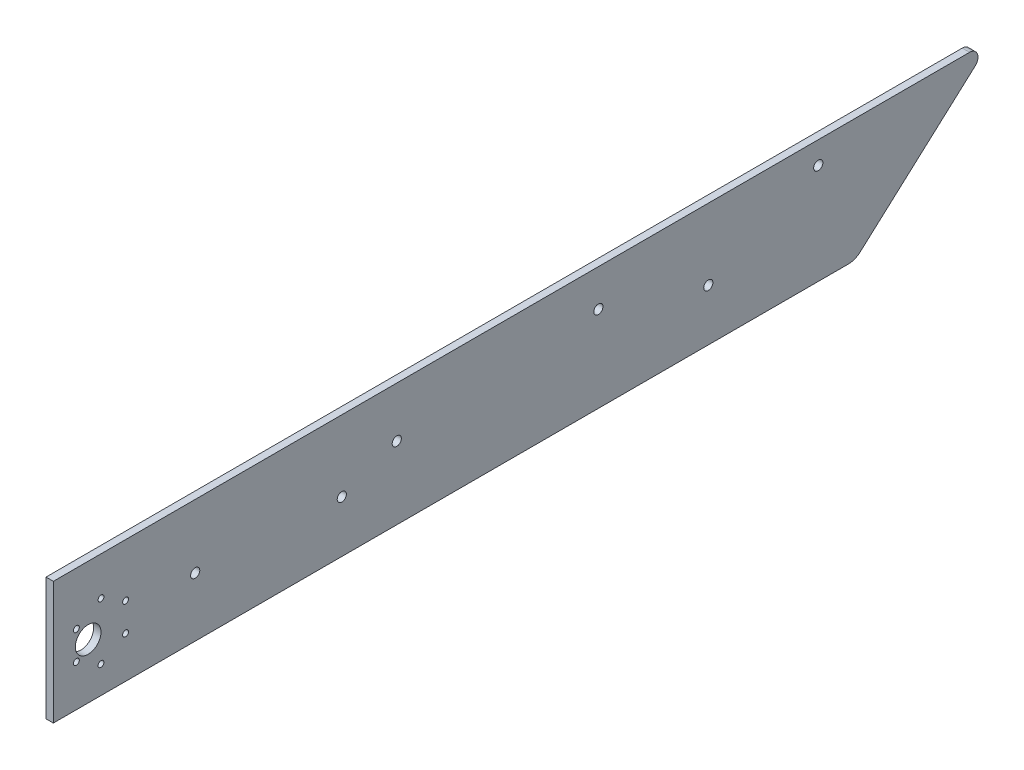
from build123d import *

# Parameters (mm, degrees)
SKETCH_1_R      = 2.5
SKETCH_1_R_2    = 7
SKETCH_1_R_3    = 1.6
EXTRUDE_1_DEPTH = 4


with BuildPart() as part:
    # 草图1 → 凸台-拉伸1 (new body)
    with BuildSketch(Plane.ZY):
        with BuildLine():
            Line((-207.252247772, -7.404631077), (226.406668198, -7.404631077))
            Line((226.406668198, -7.404631077), (226.406668198, 59.595368923))
            Line((226.406668198, 59.595368923), (-273.593331802, 59.595368923))
            ThreePointArc((-273.593331802, 59.595368923), (-277.860990507, 56.662288358), (-276.652116001, 51.626963655))
            Line((-276.652116001, 51.626963655), (-213.943553835, -4.836079331))
            ThreePointArc((-213.943553835, -4.836079331), (-210.835927267, -6.740435342), (-207.252247772, -7.404631077))
        make_face()
        with Locations((-191.007742204, 47.443421044)):
            Circle(SKETCH_1_R, mode=Mode.SUBTRACT)
        with Locations((68.992257796, 20.828748174)):
            Circle(SKETCH_1_R, mode=Mode.SUBTRACT)
        with Locations((38.992257796, 32.145259985)):
            Circle(SKETCH_1_R, mode=Mode.SUBTRACT)
        with Locations((-131.007742204, 20.828748174)):
            Circle(SKETCH_1_R, mode=Mode.SUBTRACT)
        with Locations((207.406668198, 22.602258186)):
            Circle(SKETCH_1_R_2, mode=Mode.SUBTRACT)
        with Locations((148.992257796, 24.828748174)):
            Circle(SKETCH_1_R, mode=Mode.SUBTRACT)
        with Locations((-71.007742204, 39.461771796)):
            Circle(SKETCH_1_R, mode=Mode.SUBTRACT)
        with Locations((213.830061956, 30.756889262)):
            Circle(SKETCH_1_R_3, mode=Mode.SUBTRACT)
        with Locations((200.406668198, 38.506889262)):
            Circle(SKETCH_1_R_3, mode=Mode.SUBTRACT)
        with Locations((186.983274439, 30.756889262)):
            Circle(SKETCH_1_R_3, mode=Mode.SUBTRACT)
        with Locations((186.983274439, 15.256889262)):
            Circle(SKETCH_1_R_3, mode=Mode.SUBTRACT)
        with Locations((200.406668198, 7.506889262)):
            Circle(SKETCH_1_R_3, mode=Mode.SUBTRACT)
        with Locations((213.830061956, 15.256889262)):
            Circle(SKETCH_1_R_3, mode=Mode.SUBTRACT)
    extrude(amount=EXTRUDE_1_DEPTH)


solid = part.part
